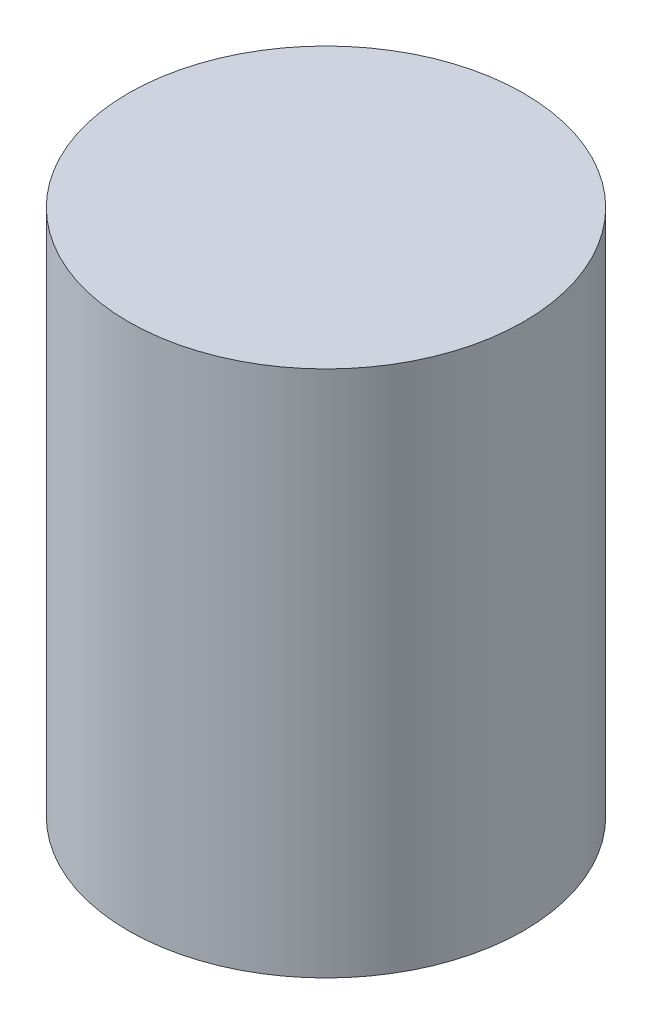
from build123d import *

# Parameters (mm, degrees)
ESBO_O1_W = 30
ESBO_O1_H = 80


with BuildPart() as part:
    # Esboço1 → Revolução1 (revolve)
    with BuildSketch(Plane.XY):
        with Locations((15, 40)):
            Rectangle(ESBO_O1_W, ESBO_O1_H)
    revolve(axis=Axis((0, 0, 0), (0, 1, 0)))


solid = part.part
